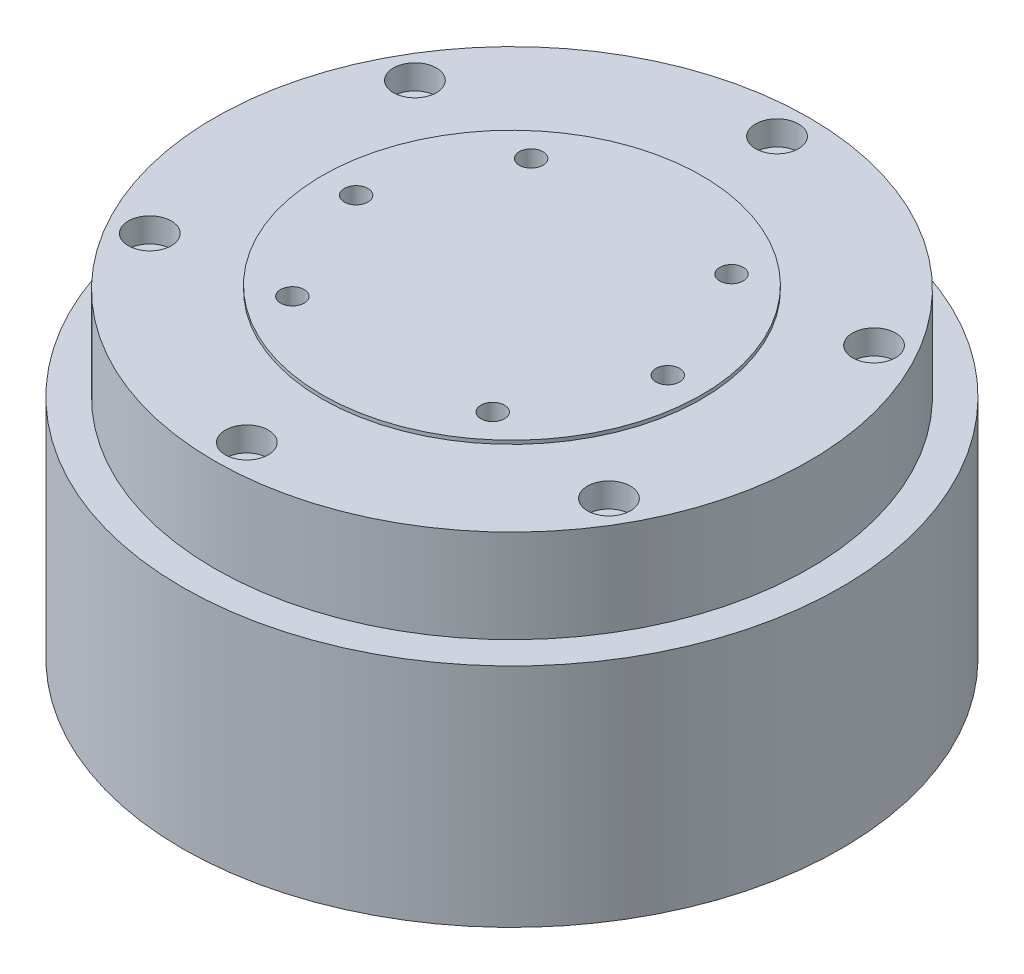
from build123d import *

# Parameters (mm, degrees)
SKETCH_1_R                   = 46
EXTRUDE_1_DEPTH              = 31.6
SKETCH_2_R                   = 41.5
EXTRUDE_2_DEPTH              = 13
SKETCH_3_R                   = 26.5
EXTRUDE_3_DEPTH              = 13.5
SKETCH_4_R                   = 1.5
CUT_EXTRUDE_1_DEPTH          = 10
HOLE_WIZARD_M4_1_D           = 3.3
HOLE_WIZARD_M4_1_DEPTH       = 10.1
HOLE_WIZARD_M4_1_TIP         = 0.991420021
HOLE_WIZARD_M3_1_D           = 3.4
HOLE_WIZARD_M3_1_DEPTH       = 7.5
HOLE_WIZARD_M3_1_CBORE_D     = 6
HOLE_WIZARD_M3_1_CBORE_DEPTH = 3.4
HOLE_WIZARD_M3_1_TIP         = 1.021463052
SKETCH_9_W                   = 30
SKETCH_9_H                   = 15
EXTRUDE_4_DEPTH              = 4


with BuildPart() as part:
    # 草图1 → 凸台-拉伸1 (new body)
    with BuildSketch(Plane(origin=(0, 0, 0), x_dir=(1, 0, 0), z_dir=(0, 1, 0))):
        Circle(SKETCH_1_R)
    extrude(amount=EXTRUDE_1_DEPTH)

    # 草图2 → 凸台-拉伸2 (add)
    with BuildSketch(Plane(origin=(0, 31.6, 0), x_dir=(1, 0, 0), z_dir=(0, 1, 0))):
        Circle(SKETCH_2_R)
    extrude(amount=EXTRUDE_2_DEPTH)

    # 草图3 → 凸台-拉伸3 (add)
    with BuildSketch(Plane(origin=(0, 31.6, 0), x_dir=(1, 0, 0), z_dir=(0, 1, 0))):
        Circle(SKETCH_3_R)
    extrude(amount=EXTRUDE_3_DEPTH)

    # 草图4 → 切除-拉伸1 (cut)
    with BuildSketch(Plane(origin=(0, 45.1, 0), x_dir=(1, 0, 0), z_dir=(0, 1, 0))):
        with Locations((-21.75, 0)):
            Circle(SKETCH_4_R)
        with Locations((21.75, 0)):
            Circle(SKETCH_4_R)
        with Locations((13.980630511, 16.661466638)):
            Circle(SKETCH_4_R)
        with Locations((-13.980630511, 16.661466638)):
            Circle(SKETCH_4_R)
        with Locations((13.980630511, -16.661466638)):
            Circle(SKETCH_4_R)
        with Locations((-13.980630511, -16.661466638)):
            Circle(SKETCH_4_R)
    extrude(amount=-CUT_EXTRUDE_1_DEPTH, mode=Mode.SUBTRACT)

    # M4 螺纹孔1
    with Locations(Plane(origin=(-13.980630511, 45.1, 16.661466638), x_dir=(0, 0, 1), z_dir=(0, 1, 0))):
        with Locations((0, 0), (-16.661466638, -7.769369489), (-33.322933276, 0), (-33.322933276, 27.961261022), (-16.661466638, 35.730630511), (0, 27.961261022)):
            Hole(HOLE_WIZARD_M4_1_D / 2, depth=HOLE_WIZARD_M4_1_DEPTH)
            with Locations((0, 0, -(HOLE_WIZARD_M4_1_DEPTH + HOLE_WIZARD_M4_1_TIP / 2))):  # 118° drill point
                Cone(0, HOLE_WIZARD_M4_1_D / 2, HOLE_WIZARD_M4_1_TIP, mode=Mode.SUBTRACT)

    # M3 六角圆柱头螺钉的柱形沉头孔1
    with Locations(Plane(origin=(32.04293994, 44.6, -18.5), x_dir=(0, 0, 1), z_dir=(0, 1, 0))):
        with Locations((0, 0), (37, 0), (55.5, -32.04293994), (37, -64.08587988), (0, -64.08587988), (-18.5, -32.04293994)):
            CounterBoreHole(HOLE_WIZARD_M3_1_D / 2, HOLE_WIZARD_M3_1_CBORE_D / 2, HOLE_WIZARD_M3_1_CBORE_DEPTH, depth=HOLE_WIZARD_M3_1_DEPTH)
            with Locations((0, 0, -(HOLE_WIZARD_M3_1_DEPTH + HOLE_WIZARD_M3_1_TIP / 2))):  # 118° drill point
                Cone(0, HOLE_WIZARD_M3_1_D / 2, HOLE_WIZARD_M3_1_TIP, mode=Mode.SUBTRACT)

    # 草图9 → 凸台-拉伸4 (add)
    with BuildSketch(Plane.XZ):
        with Locations((1.722788181, -26.5)):
            Rectangle(SKETCH_9_W, SKETCH_9_H)
    extrude(amount=EXTRUDE_4_DEPTH)


solid = part.part
